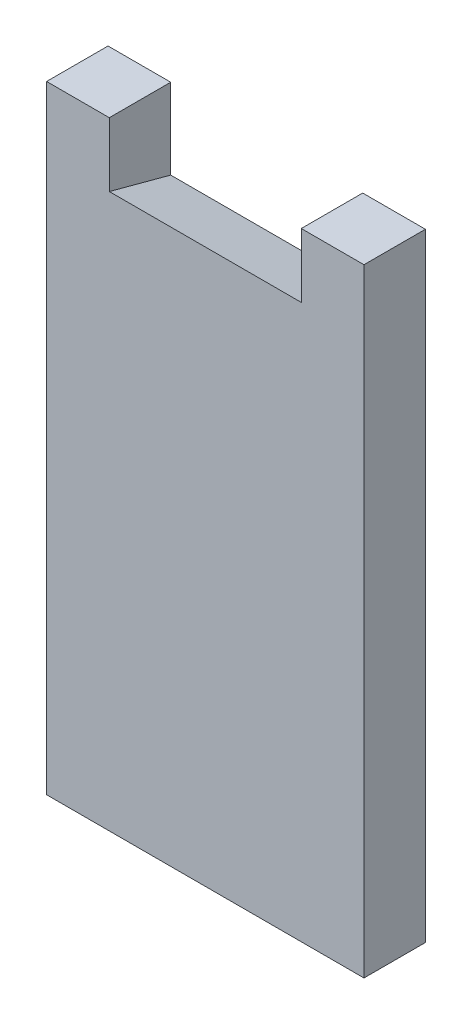
from build123d import *

# Parameters (mm, degrees)
EXTRUDE_1_DEPTH = 9.6
DRAFT_5_ANGLE   = -15


with BuildPart() as part:
    # 草图1 → 凸台-拉伸1 (new body)
    with BuildSketch(Plane.XY):
        Polygon((9.8, 0), (0, 0), (0, -96.54), (49.6, -96.54), (49.6, 0), (39.8, 0), (39.8, -10), (9.8, -10), align=None)
    extrude(amount=EXTRUDE_1_DEPTH)

    # 拔模5
    draft_5_faces = [part.faces().sort_by_distance(p)[0] for p in [
        (24.8, -10, 4.8),
    ]]
    draft(draft_5_faces, Plane.XY.offset(9.6), DRAFT_5_ANGLE)


solid = part.part
